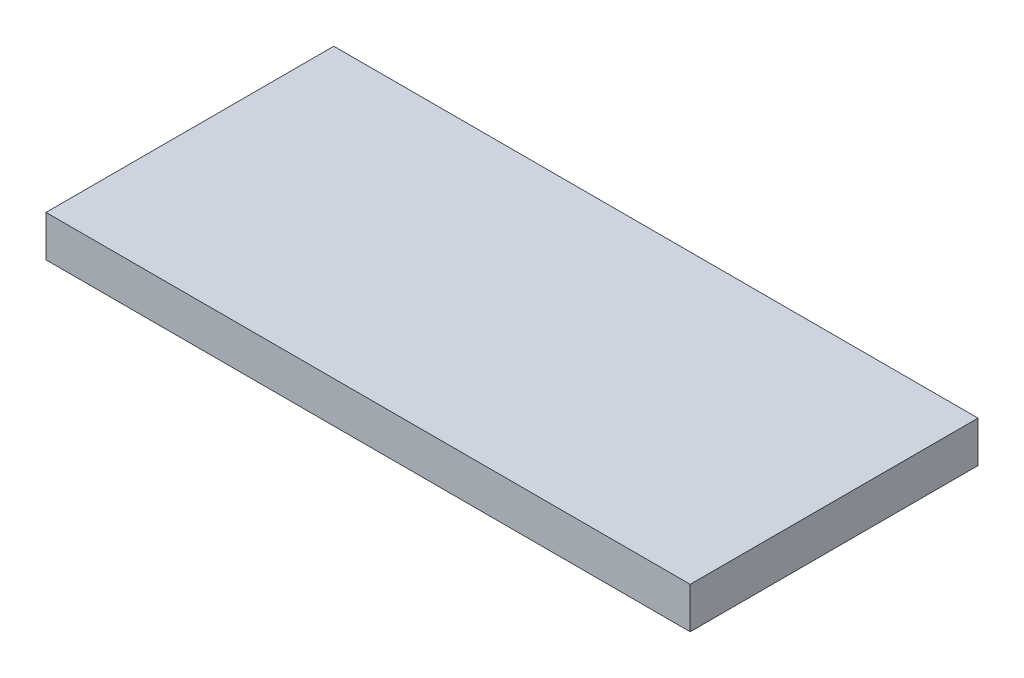
from build123d import *

# Parameters (mm, degrees)
SKETCH1_W           = 94
SKETCH1_H           = 42
BOSS_EXTRUDE1_DEPTH = 6


with BuildPart() as part:
    # Sketch1 → Boss-Extrude1 (new body)
    with BuildSketch(Plane(origin=(0, 0, 0), x_dir=(1, 0, 0), z_dir=(0, 1, 0))):
        Rectangle(SKETCH1_W, SKETCH1_H)
    extrude(amount=BOSS_EXTRUDE1_DEPTH)


solid = part.part
